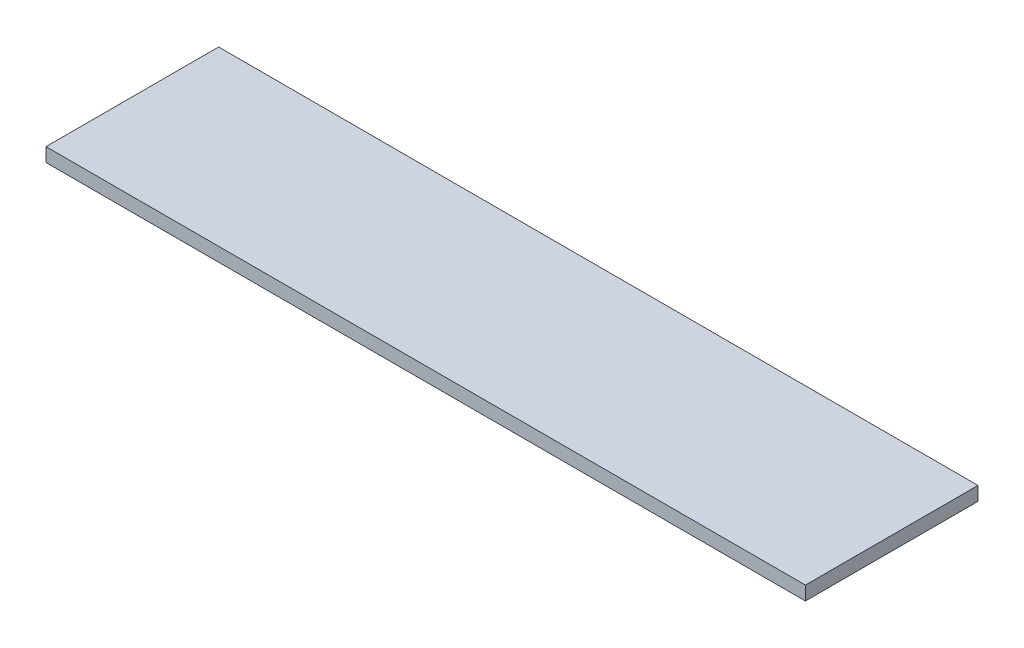
from build123d import *

# Parameters (mm, degrees)
SKETCH1_W           = 25
SKETCH1_H           = 2
BOSS_EXTRUDE1_DEPTH = 110


with BuildPart() as part:
    # Sketch1 → Boss-Extrude1 (new body)
    with BuildSketch(Plane(origin=(0, 0, 0), x_dir=(0, 0, -1), z_dir=(1, 0, 0))):
        Rectangle(SKETCH1_W, SKETCH1_H)
    extrude(amount=BOSS_EXTRUDE1_DEPTH)


solid = part.part
